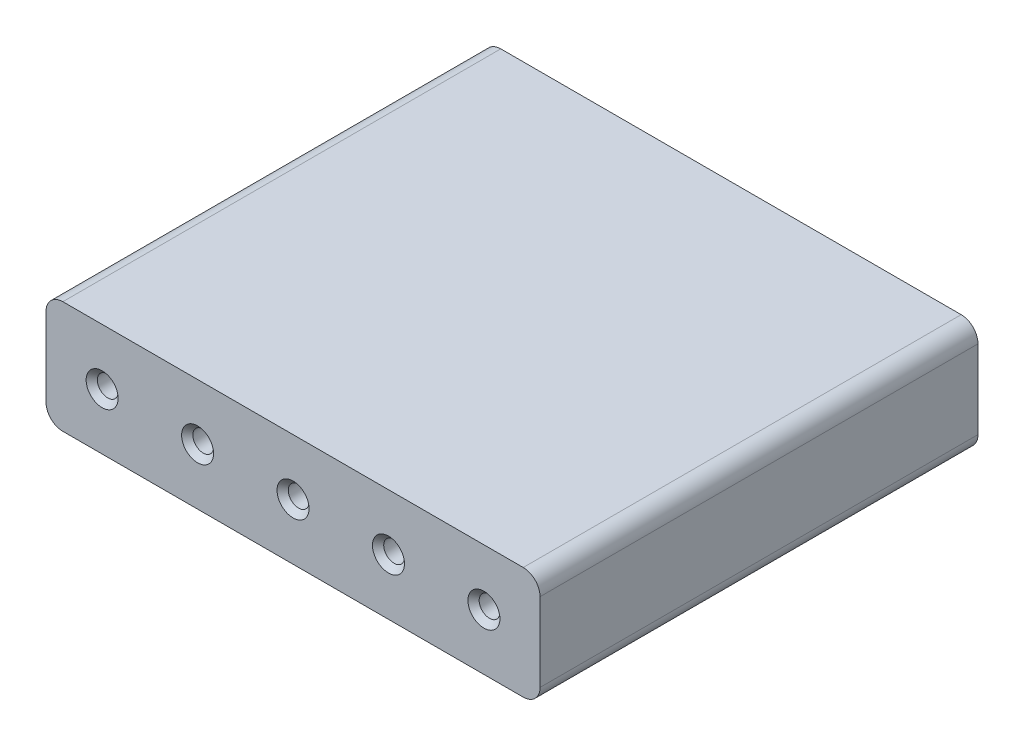
from build123d import *

# Parameters (mm, degrees)
SKETCH1_R           = 1.85
BOSS_EXTRUDE1_DEPTH = 78
CHAMFER1_SIZE       = 1


with BuildPart() as part:
    # Sketch1 → Boss-Extrude1 (new body)
    with BuildSketch(Plane.XY):
        with BuildLine():
            Line((41, -10), (-41, -10))
            ThreePointArc((-41, -10), (-43.121320344, -9.121320344), (-44, -7))
            Line((-44, -7), (-44, 7))
            ThreePointArc((-44, 7), (-43.121320344, 9.121320344), (-41, 10))
            Line((-41, 10), (41, 10))
            ThreePointArc((41, 10), (43.121320344, 9.121320344), (44, 7))
            Line((44, 7), (44, -7))
            ThreePointArc((44, -7), (43.121320344, -9.121320344), (41, -10))
        make_face()
        with Locations((-34, 0)):
            Circle(SKETCH1_R, mode=Mode.SUBTRACT)
        with Locations((-17, 0)):
            Circle(SKETCH1_R, mode=Mode.SUBTRACT)
        Circle(SKETCH1_R, mode=Mode.SUBTRACT)
        with Locations((17, 0)):
            Circle(SKETCH1_R, mode=Mode.SUBTRACT)
        with Locations((34, 0)):
            Circle(SKETCH1_R, mode=Mode.SUBTRACT)
    extrude(amount=BOSS_EXTRUDE1_DEPTH)

    # Chamfer1
    chamfer1_edges = [part.edges().sort_by_distance(p)[0] for p in [
        (-35.85, 0, 0),
        (-35.85, 0, 78),
        (-18.85, 0, 0),
        (-18.85, 0, 78),
        (-1.85, 0, 0),
        (-1.85, 0, 78),
        (15.15, 0, 0),
        (15.15, 0, 78),
        (32.15, 0, 0),
        (32.15, 0, 78),
    ]]
    chamfer(chamfer1_edges, length=CHAMFER1_SIZE)


solid = part.part
